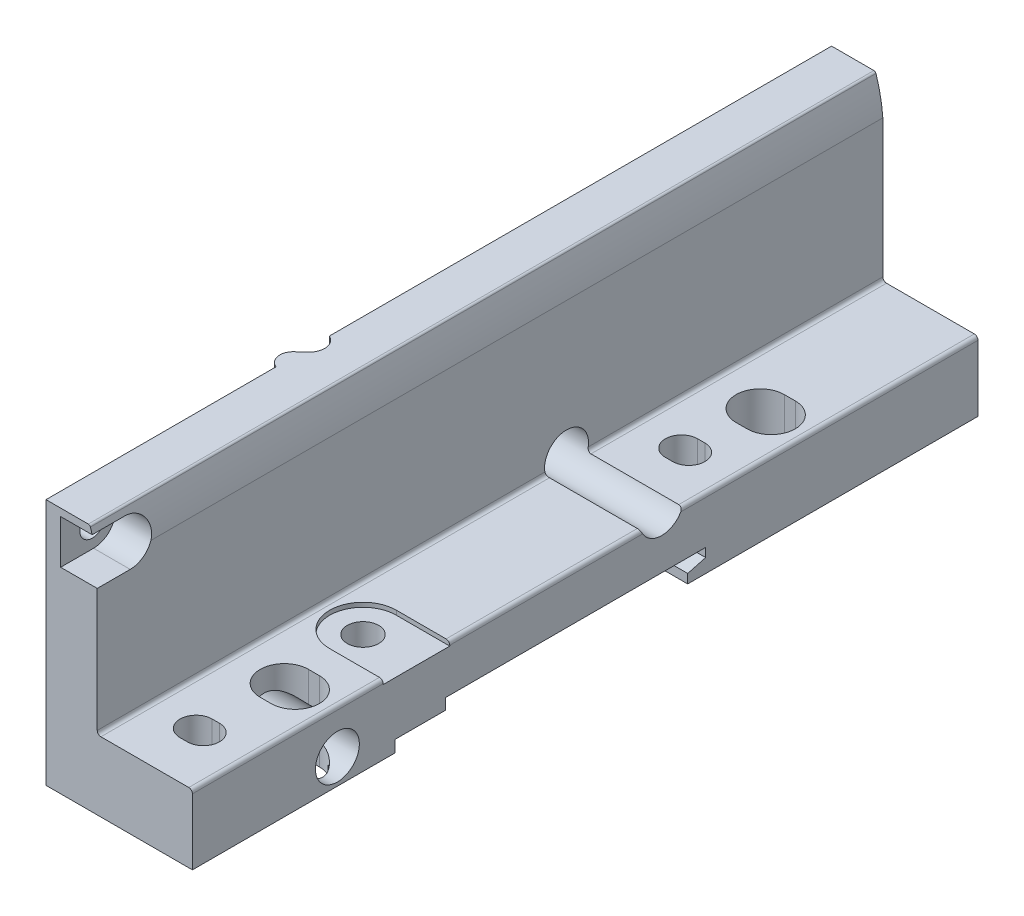
from build123d import *

# Parameters (mm, degrees)
BOSS_EXTRUDE1_DEPTH      = 53.65
BOSS_EXTRUDE1_DEPTH_BACK = 53.65
CUT_EXTRUDE1_DEPTH       = 50
CUT_EXTRUDE2_DEPTH       = 40
CUT_EXTRUDE2_DEPTH_BACK  = 40
SKETCH4_W                = 8
SKETCH4_H                = 19.5
BOSS_EXTRUDE2_DEPTH      = 1.5
SKETCH5_W                = 16.8
SKETCH5_H                = 20.35
BOSS_EXTRUDE3_DEPTH      = 1.5
CUT_EXTRUDE3_DEPTH       = 30
CUT_EXTRUDE3_DEPTH_BACK  = 30
CUT_EXTRUDE4_DEPTH       = 30
SKETCH8_R                = 2.15
CUT_EXTRUDE5_DEPTH       = 30
CUT_EXTRUDE6_DEPTH       = 10.8
CUT_EXTRUDE7_DEPTH       = 10.8
SKETCH13_W               = 20
SKETCH13_H               = 1.715
CUT_EXTRUDE8_DEPTH       = 5
CUT_EXTRUDE8_DEPTH_BACK  = 5
CUT_EXTRUDE9_DEPTH       = 0.6
SKETCH16_W               = 12
SKETCH16_H               = 2.5
CUT_EXTRUDE10_DEPTH      = 3.5


with BuildPart() as part:
    # Sketch1 → Boss-Extrude1 (new body, two sides)
    with BuildSketch(Plane.XY) as boss_extrude1_sk:
        with BuildLine():
            Line((-5, 1.3), (20, 1.3))
            Line((20, 1.3), (20, 10.3))
            ThreePointArc((20, 10.3), (19.853553391, 10.653553391), (19.5, 10.8))
            Line((19.5, 10.8), (7.5, 10.8))
            ThreePointArc((7.5, 10.8), (7.146446609, 10.946446609), (7, 11.3))
            Line((7, 11.3), (7, 30.113329403))
            ThreePointArc((7, 30.113329403), (6.679537553, 32.531612644), (6.067046966, 34.89289308))
            ThreePointArc((6.067046966, 34.89289308), (5.958046762, 35.042763181), (5.781791158, 35.1))
            Line((5.781791158, 35.1), (-5, 35.1))
            Line((-5, 35.1), (-5, 1.3))
        make_face()
    extrude(amount=BOSS_EXTRUDE1_DEPTH)
    extrude(boss_extrude1_sk.sketch, amount=-BOSS_EXTRUDE1_DEPTH_BACK)

    # Sketch2 → Cut-Extrude1 (cut)
    with BuildSketch(Plane(origin=(0, 0, 0), x_dir=(1, 0, 0), z_dir=(0, 1, 0))):
        with BuildLine():
            Line((-50, 53.65), (-50, -53.65))
            Line((-50, -53.65), (0, -53.65))
            Line((0, -53.65), (0, -22.228541033))
            ThreePointArc((0, -22.228541033), (-1.117187677, -20.892122365), (-0.57947873, -19.235320551))
            Line((-0.57947873, -19.235320551), (0.516087478, -18.210754943))
            ThreePointArc((0.516087478, -18.210754943), (1.125563929, -16.438315605), (0, -14.939613301))
            Line((0, -14.939613301), (0, 53.65))
            Line((0, 53.65), (-50, 53.65))
        make_face()
    extrude(amount=CUT_EXTRUDE1_DEPTH, mode=Mode.SUBTRACT)

    # Sketch3 → Cut-Extrude2 (cut, two sides)
    with BuildSketch(Plane(origin=(0, 0, 0), x_dir=(0, 0, -1), z_dir=(1, 0, 0))) as cut_extrude2_sk:
        Polygon((-26, 2.9), (-26, -8.174443219), (14, -7.963716906), (14, 2.543524479), (16.45, 3.2), (16.45, 4.4), (-19.05, 4.4), (-19.05, 2.9), align=None)
    extrude(amount=CUT_EXTRUDE2_DEPTH, mode=Mode.SUBTRACT)
    extrude(cut_extrude2_sk.sketch, amount=-CUT_EXTRUDE2_DEPTH_BACK, mode=Mode.SUBTRACT)

    # Sketch4 → Boss-Extrude2 (add)
    with BuildSketch(Plane(origin=(0, 0, 0), x_dir=(1, 0, 0), z_dir=(0, 1, 0))):
        with Locations((12.8, 25.75)):
            Rectangle(SKETCH4_W, SKETCH4_H)
    extrude(amount=BOSS_EXTRUDE2_DEPTH)

    # Sketch5 → Boss-Extrude3 (add)
    with BuildSketch(Plane(origin=(0, 0, 0), x_dir=(1, 0, 0), z_dir=(0, 1, 0))):
        with Locations((8.4, -39.675)):
            Rectangle(SKETCH5_W, SKETCH5_H)
    extrude(amount=BOSS_EXTRUDE3_DEPTH)

    # Sketch6 → Cut-Extrude3 (cut, two sides)
    with BuildSketch(Plane(origin=(0, 0, 0), x_dir=(1, 0, 0), z_dir=(0, 1, 0))) as cut_extrude3_sk:
        with BuildLine():
            Line((13.7, 26.9), (15.2, 26.9))
            ThreePointArc((15.2, 26.9), (18.5, 30.2), (15.2, 33.5))
            Line((15.2, 33.5), (13.7, 33.5))
            ThreePointArc((13.7, 33.5), (10.4, 30.2), (13.7, 26.9))
        make_face()
    extrude(amount=CUT_EXTRUDE3_DEPTH, mode=Mode.SUBTRACT)
    extrude(cut_extrude3_sk.sketch, amount=-CUT_EXTRUDE3_DEPTH_BACK, mode=Mode.SUBTRACT)

    # Sketch7 → Cut-Extrude4 (cut)
    with BuildSketch(Plane(origin=(0, 0, 0), x_dir=(1, 0, 0), z_dir=(0, 1, 0))):
        with BuildLine():
            Line((13, 17.95), (14, 17.95))
            ThreePointArc((14, 17.95), (16.2, 20.15), (14, 22.35))
            Line((14, 22.35), (13, 22.35))
            ThreePointArc((13, 22.35), (10.8, 20.15), (13, 17.95))
        make_face()
    extrude(amount=CUT_EXTRUDE4_DEPTH, mode=Mode.SUBTRACT)

    # Sketch8 → Cut-Extrude5 (cut)
    with BuildSketch(Plane(origin=(0, 0, 0), x_dir=(1, 0, 0), z_dir=(0, 1, 0))):
        with Locations((12.7, -23.05)):
            Circle(SKETCH8_R)
    extrude(amount=CUT_EXTRUDE5_DEPTH, mode=Mode.SUBTRACT)

    # Sketch9 → Cut-Extrude6 (cut)
    with BuildSketch(Plane(origin=(0, 0, 0), x_dir=(1, 0, 0), z_dir=(0, 1, 0))):
        with BuildLine():
            Line((13.7, -38.1), (15.2, -38.1))
            ThreePointArc((15.2, -38.1), (18.5, -34.8), (15.2, -31.5))
            Line((15.2, -31.5), (13.7, -31.5))
            ThreePointArc((13.7, -31.5), (10.4, -34.8), (13.7, -38.1))
        make_face()
    extrude(amount=CUT_EXTRUDE6_DEPTH, mode=Mode.SUBTRACT)

    # Sketch10 → Cut-Extrude7 (cut)
    with BuildSketch(Plane(origin=(0, 0, 0), x_dir=(1, 0, 0), z_dir=(0, 1, 0))):
        with BuildLine():
            Line((13, -48.35), (14, -48.35))
            ThreePointArc((14, -48.35), (16.2, -46.15), (14, -43.95))
            Line((14, -43.95), (13, -43.95))
            ThreePointArc((13, -43.95), (10.8, -46.15), (13, -48.35))
        make_face()
    extrude(amount=CUT_EXTRUDE7_DEPTH, mode=Mode.SUBTRACT)

    # Sketch11 → Cut-Revolve1 (revolve, cut)
    with BuildSketch(Plane(origin=(0, 11.8, 0), x_dir=(1, 0, 0), z_dir=(0, 1, 0))):
        Polygon((0, 10.45), (0, 12.2), (2, 12.2), (2, 13.45), (20, 13.45), (20, 10.45), align=None)
    revolve(axis=Axis((20, 11.8, -10.45), (-1, 0, 0)), mode=Mode.SUBTRACT)

    # Sketch12 → Cut-Revolve2 (revolve, cut)
    with BuildSketch(Plane(origin=(0, 4.8, 0), x_dir=(1, 0, 0), z_dir=(0, 1, 0))):
        Polygon((0, -33.85), (0, -32.1), (2, -32.1), (2, -30.85), (20, -30.85), (20, -33.85), align=None)
    revolve(axis=Axis((20, 4.8, 33.85), (-1, 0, 0)), mode=Mode.SUBTRACT)

    # Sketch13 → Cut-Revolve3 (revolve, cut)
    with BuildSketch(Plane(origin=(0, 31.1, 0), x_dir=(1, 0, 0), z_dir=(0, 1, 0))):
        with Locations((10, -48.4625)):
            Rectangle(SKETCH13_W, SKETCH13_H)
    revolve(axis=Axis((20, 31.1, 49.32), (-1, 0, 0)), mode=Mode.SUBTRACT)

    # Sketch14 → Cut-Extrude8 (cut, two sides)
    with BuildSketch(Plane(origin=(7, 0, 0), x_dir=(0, 0, -1), z_dir=(1, 0, 0))) as cut_extrude8_sk:
        with BuildLine():
            Line((-54.15, 28.1), (-49.15, 28.1))
            ThreePointArc((-49.15, 28.1), (-46.15, 31.1), (-49.15, 34.1))
            Line((-49.15, 34.1), (-54.15, 34.1))
            Line((-54.15, 34.1), (-54.15, 28.1))
        make_face()
    extrude(amount=CUT_EXTRUDE8_DEPTH, mode=Mode.SUBTRACT)
    extrude(cut_extrude8_sk.sketch, amount=-CUT_EXTRUDE8_DEPTH_BACK, mode=Mode.SUBTRACT)

    # Sketch15 → Cut-Extrude9 (cut)
    with BuildSketch(Plane(origin=(0, 10.8, 0), x_dir=(1, 0, 0), z_dir=(0, 1, 0))):
        with BuildLine():
            Line((12.7, -27.6), (20, -27.6))
            Line((20, -27.6), (20, -18.5))
            Line((20, -18.5), (12.7, -18.5))
            ThreePointArc((12.7, -18.5), (8.15, -23.05), (12.7, -27.6))
        make_face()
    extrude(amount=-CUT_EXTRUDE9_DEPTH, mode=Mode.SUBTRACT)

    # Sketch16 → Cut-Extrude10 (cut)
    with BuildSketch(Plane(origin=(0, 0, 0), x_dir=(1, 0, 0), z_dir=(0, 1, 0))):
        with Locations((9.65, 15.2)):
            Rectangle(SKETCH16_W, SKETCH16_H)
    extrude(amount=CUT_EXTRUDE10_DEPTH, mode=Mode.SUBTRACT)


solid = part.part
